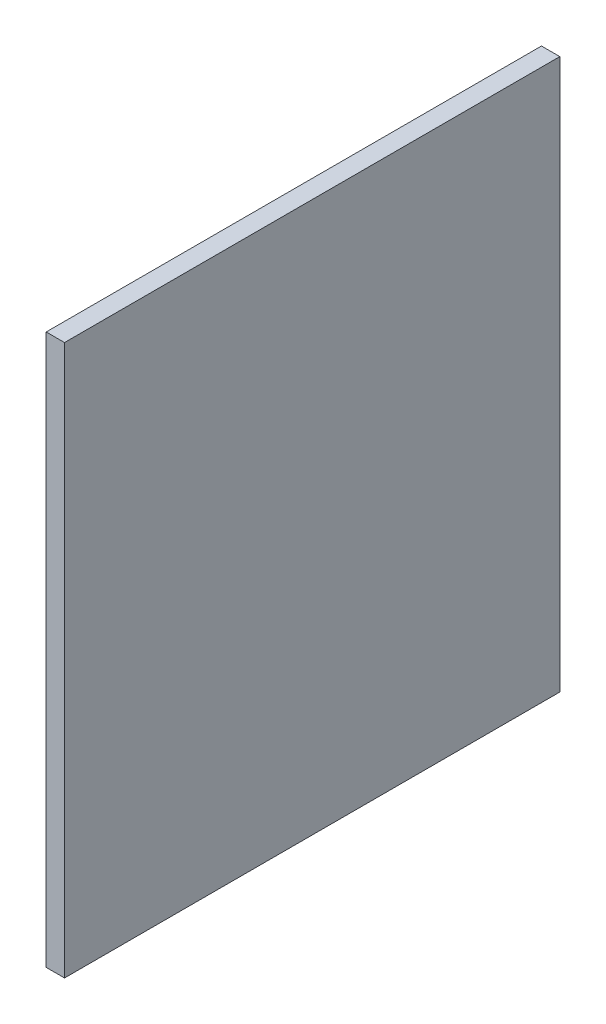
from build123d import *

# Parameters (mm, degrees)
EXTRUDE_1_DEPTH = 10


with BuildPart() as part:
    # 草图1 → 凸台-拉伸1 (new body)
    with BuildSketch(Plane(origin=(0, 0, 0), x_dir=(0, 0, -1), z_dir=(1, 0, 0))):
        Polygon((-44.128510002, 33.686834396), (-44.128510002, -266.313165604), (205.871489998, -266.313165604), (225.871489998, -266.313165604), (225.871489998, 33.686834396), align=None)
    extrude(amount=EXTRUDE_1_DEPTH)


solid = part.part
